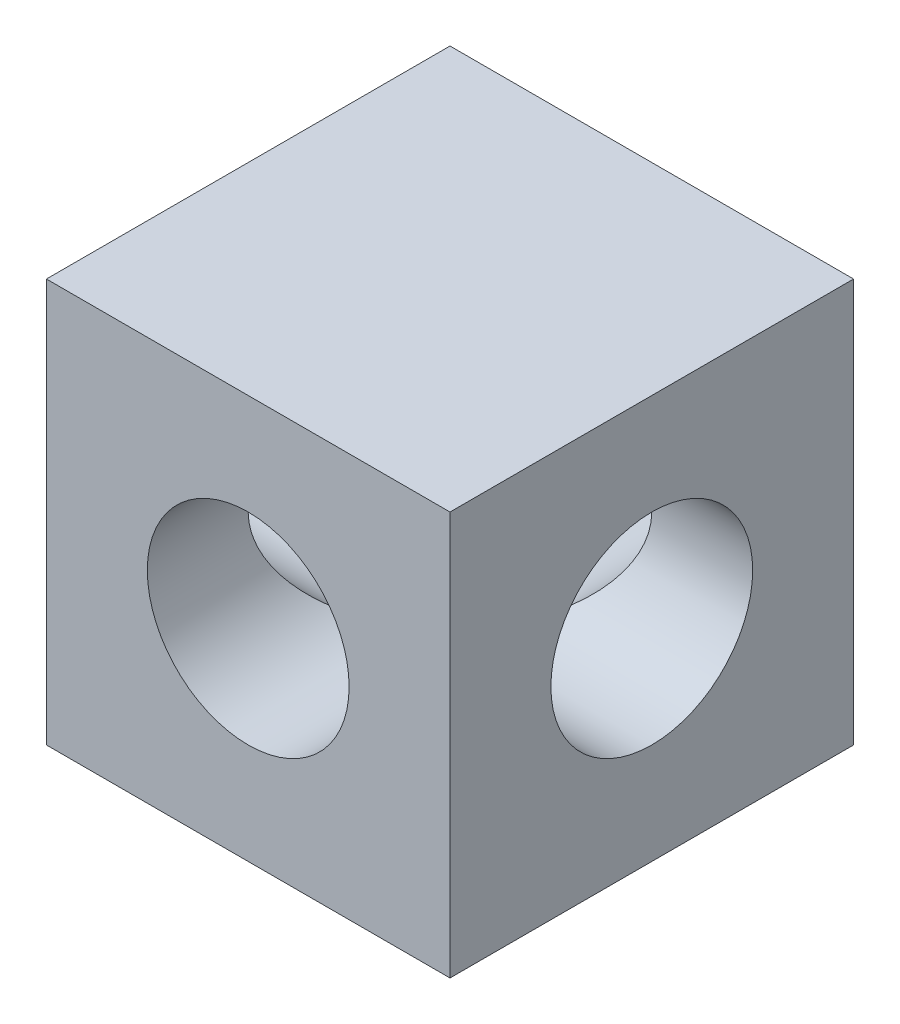
from build123d import *

# Parameters (mm, degrees)
SKETCH1_W          = 19.05
SKETCH1_H          = 19.05
SKETCH1_R          = 4.7625
BASE_EXTRUDE_DEPTH = 9.525
SKETCH3_R          = 4.7625
CUT_EXTRUDE1_DEPTH = 24.3313898
SCALE1_SCALE       = 0.65


with BuildPart() as part:
    # Sketch1 → Base-Extrude (new, symmetric)
    with BuildSketch(Plane.XY):
        Rectangle(SKETCH1_W, SKETCH1_H)
        with Locations(Location((0, 0, 0), (0, 0, 180))):
            Circle(SKETCH1_R, mode=Mode.SUBTRACT)
    extrude(amount=BASE_EXTRUDE_DEPTH, both=True)

    # Sketch3 → Cut-Extrude1 (cut, through all)
    with BuildSketch(Plane(origin=(9.525, 0, 0), x_dir=(0, 0, -1), z_dir=(1, 0, 0))):
        Circle(SKETCH3_R)
    extrude(amount=-CUT_EXTRUDE1_DEPTH, mode=Mode.SUBTRACT)


with BuildPart() as part_1:
    # Scale1: scaled about (0, 0, 0)
    add(part.part.scale(SCALE1_SCALE))


solid = part_1.part
